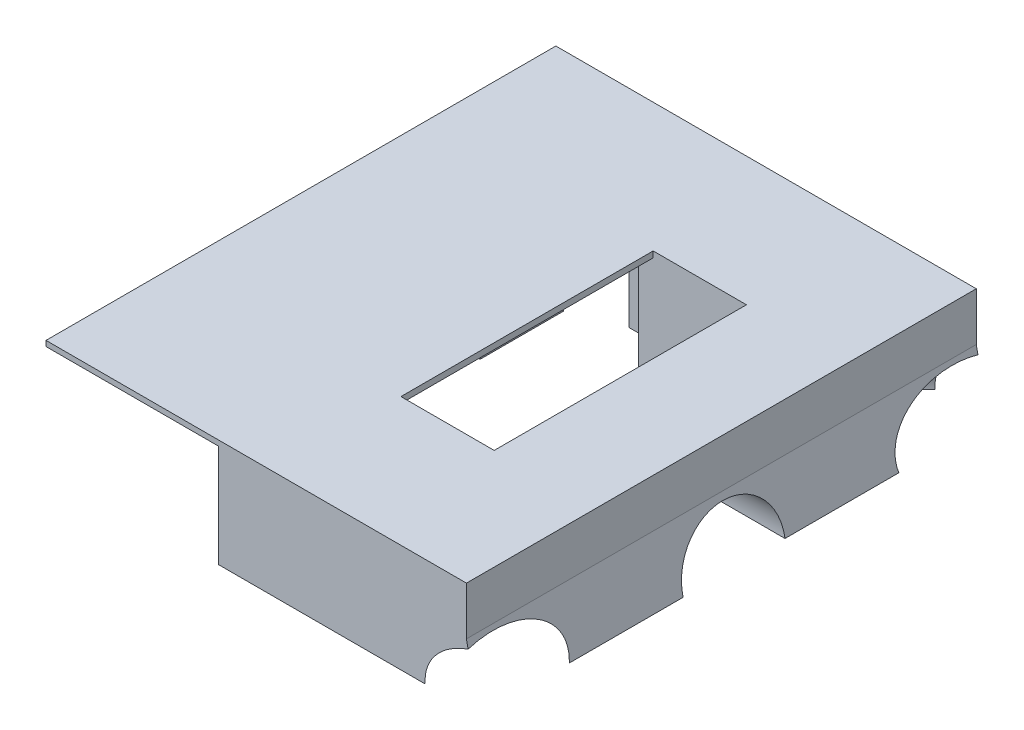
from build123d import *

# Parameters (mm, degrees)
SKETCH1_W           = 95
SKETCH1_H           = 95
BOSS_EXTRUDE1_DEPTH = 50
CUT_EXTRUDE1_DEPTH  = 100
SKETCH3_R           = 9.5
CUT_EXTRUDE2_DEPTH  = 45
CUT_EXTRUDE4_DEPTH  = 45
CUT_EXTRUDE5_DEPTH  = 45
CUT_EXTRUDE6_DEPTH  = 45
CUT_EXTRUDE7_DEPTH  = 45
SKETCH9_R           = 9.5
CUT_EXTRUDE9_DEPTH  = 45
SKETCH11_R          = 9.5
CUT_EXTRUDE10_DEPTH = 45
SKETCH12_W          = 31.985759797
SKETCH12_H          = 95
BOSS_EXTRUDE2_DEPTH = 45
CUT_EXTRUDE11_DEPTH = 100
SKETCH14_R          = 9.5
CUT_EXTRUDE12_DEPTH = 100
SKETCH15_R          = 9.5
CUT_EXTRUDE13_DEPTH = 100
SKETCH16_R          = 9.5
CUT_EXTRUDE14_DEPTH = 100
FILLET2_R           = 4
SKETCH17_W          = 34
SKETCH17_H          = 34
CUT_EXTRUDE16_DEPTH = 22
SKETCH19_W          = 34
SKETCH19_H          = 34
CUT_EXTRUDE17_DEPTH = 22
SKETCH20_W          = 12.5
SKETCH20_H          = 16.5
CUT_EXTRUDE18_DEPTH = 60
CUT_EXTRUDE19_DEPTH = 60
SKETCH22_W          = 99.816433395
SKETCH22_H          = 26.367590903
CUT_EXTRUDE21_DEPTH = 100
SKETCH23_R          = 1
CUT_EXTRUDE24_DEPTH = 909
SKETCH25_R          = 1
CUT_EXTRUDE25_DEPTH = 789
SKETCH27_W          = 26.129652456
SKETCH27_H          = 47
CUT_EXTRUDE27_DEPTH = 9
SKETCH28_W          = 2
SKETCH28_H          = 20
CUT_EXTRUDE28_DEPTH = 5
SKETCH29_W          = 99.017305209
SKETCH29_H          = 17.897343585
CUT_EXTRUDE29_DEPTH = 447
CUT_EXTRUDE30_DEPTH = 447
SKETCH31_W          = 26.129652456
SKETCH31_H          = 47
CUT_EXTRUDE31_DEPTH = 447
SKETCH32_W          = 12.716067022
SKETCH32_H          = 47
CUT_EXTRUDE32_DEPTH = 90
BOSS_EXTRUDE4_DEPTH = 9
SKETCH37_W          = 36.129652456
SKETCH37_H          = 47
CUT_EXTRUDE34_DEPTH = 9
SKETCH38_W          = 16
SKETCH38_H          = 58
CUT_EXTRUDE36_DEPTH = 19
SKETCH40_W          = 8.75
SKETCH40_H          = 1.118077743
BOSS_EXTRUDE5_DEPTH = 48
SKETCH41_W          = 47
SKETCH41_H          = 1.118077743
BOSS_EXTRUDE6_DEPTH = 10
SKETCH42_W          = 32.132900769
SKETCH42_H          = 1
BOSS_EXTRUDE7_DEPTH = 22
SKETCH43_W          = 32.132900769
SKETCH43_H          = 1.118077743
BOSS_EXTRUDE8_DEPTH = 22


with BuildPart() as part:
    # Sketch1 → Boss-Extrude1 (new body)
    with BuildSketch(Plane(origin=(0, 0, 0), x_dir=(1, 0, 0), z_dir=(0, 1, 0))):
        with Locations((-8.446550514, 2.043801884)):
            Rectangle(SKETCH1_W, SKETCH1_H)
    extrude(amount=BOSS_EXTRUDE1_DEPTH)

    # Sketch2 → Cut-Extrude1 (cut)
    with BuildSketch(Plane.XY.offset(45.456198116)):
        Polygon((39.053449486, 0), (36.353449486, 50), (39.053449486, 50), align=None)
    extrude(amount=-CUT_EXTRUDE1_DEPTH, mode=Mode.SUBTRACT)

    # Sketch3 → Cut-Extrude2 (cut)
    with BuildSketch(Plane(origin=(38.939900735, 2.10275464, 0), x_dir=(0, 0, -1), z_dir=(0.998545181, 0.05392144, 0))):
        with Locations((2.043801884, 13.394181776)):
            Circle(SKETCH3_R)
    extrude(amount=-CUT_EXTRUDE2_DEPTH, mode=Mode.SUBTRACT)

    # Sketch5 → Cut-Extrude4 (cut)
    with BuildSketch(Plane(origin=(0, 50, 0), x_dir=(1, 0, 0), z_dir=(0, 1, 0))):
        Polygon((39.053449486, 49.543801884), (39.053449486, 29.543801884), (19.053449486, 49.543801884), align=None)
        Polygon((39.053449486, -45.456198116), (39.053449486, -25.456198116), (19.053449486, -45.456198116), align=None)
    extrude(amount=-CUT_EXTRUDE4_DEPTH, mode=Mode.SUBTRACT)

    # Sketch6 → Cut-Extrude5 (cut)
    with BuildSketch(Plane(origin=(0, 50, 0), x_dir=(1, 0, 0), z_dir=(0, 1, 0))):
        Polygon((19.053449486, -45.456198116), (12.925569587, -39.328318218), (6.797689689, -45.456198116), align=None)
        Polygon((19.053449486, 49.543801884), (12.925569587, 43.415921985), (6.797689689, 49.543801884), align=None)
    extrude(amount=-CUT_EXTRUDE5_DEPTH, mode=Mode.SUBTRACT)

    # Sketch7 → Cut-Extrude6 (cut)
    with BuildSketch(Plane(origin=(-13.201374315, 0, 13.201374315), x_dir=(0.707106781, 0, 0.707106781), z_dir=(-0.707106781, 0, 0.707106781))):
        Polygon((45.615209271, 5), (42.915209271, 50), (45.615209271, 50), align=None)
    extrude(amount=-CUT_EXTRUDE6_DEPTH, mode=Mode.SUBTRACT)

    # Sketch8 → Cut-Extrude7 (cut)
    with BuildSketch(Plane(origin=(-15.245176199, 0, -15.245176199), x_dir=(-0.707106781, 0, 0.707106781), z_dir=(-0.707106781, 0, -0.707106781))):
        Polygon((-48.505581614, 5), (-45.805581614, 50), (-48.505581614, 50), align=None)
    extrude(amount=-CUT_EXTRUDE7_DEPTH, mode=Mode.SUBTRACT)

    # Sketch9 → Cut-Extrude9 (cut)
    with BuildSketch(Plane(origin=(34.386964646, 2.917830706, -34.386964646), x_dir=(-0.708373873, 0.059677836, -0.70331004), z_dir=(0.705837415, 0.059892291, -0.705837415))):
        with Locations((14.526974541, 11.311121921)):
            Circle(SKETCH9_R)
    extrude(amount=-CUT_EXTRUDE9_DEPTH, mode=Mode.SUBTRACT)

    # Sketch11 → Cut-Extrude10 (cut)
    with BuildSketch(Plane(origin=(32.350494057, 2.745030447, 32.350494057), x_dir=(0.70331004, 0.059677836, -0.708373873), z_dir=(0.705837415, 0.059892291, 0.705837415))):
        with Locations((-10.17752107, 12.964151979)):
            Circle(SKETCH11_R)
    extrude(amount=-CUT_EXTRUDE10_DEPTH, mode=Mode.SUBTRACT)

    # Sketch12 → Boss-Extrude2 (add)
    with BuildSketch(Plane(origin=(0, 5, 0), x_dir=(1, 0, 0), z_dir=(0, 1, 0))):
        with Locations((22.790569588, 2.043801884)):
            Rectangle(SKETCH12_W, SKETCH12_H)
    extrude(amount=BOSS_EXTRUDE2_DEPTH)

    # Sketch13 → Cut-Extrude11 (cut)
    with BuildSketch(Plane.XY.offset(45.456198116)):
        Polygon((39.053449486, 0), (29.053449486, 3), (19.053449486, 50), (49.745275601, 50), align=None)
    extrude(amount=-CUT_EXTRUDE11_DEPTH, mode=Mode.SUBTRACT)

    # Sketch14 → Cut-Extrude12 (cut)
    with BuildSketch(Plane(origin=(-5.994632406, -0.32371015, 0), x_dir=(0, 0, -1), z_dir=(0.998545181, 0.05392144, 0))):
        with Locations((2.043801884, 13.394181776)):
            Circle(SKETCH14_R)
    extrude(amount=CUT_EXTRUDE12_DEPTH, mode=Mode.SUBTRACT)

    # Sketch15 → Cut-Extrude13 (cut)
    with BuildSketch(Plane(origin=(0.587810371, 0.049877364, 0.587810371), x_dir=(0.70331004, 0.059677836, -0.708373873), z_dir=(0.705837415, 0.059892291, 0.705837415))):
        with Locations((-10.17752107, 12.964151979)):
            Circle(SKETCH15_R)
    extrude(amount=CUT_EXTRUDE13_DEPTH, mode=Mode.SUBTRACT)

    # Sketch16 → Cut-Extrude14 (cut)
    with BuildSketch(Plane(origin=(2.62428096, 0.222677624, -2.62428096), x_dir=(-0.708373873, 0.059677836, -0.70331004), z_dir=(0.705837415, 0.059892291, -0.705837415))):
        with Locations((14.526974541, 11.311121921)):
            Circle(SKETCH16_R)
    extrude(amount=CUT_EXTRUDE14_DEPTH, mode=Mode.SUBTRACT)

    # Fillet2
    fillet2_edges = [part.edges().sort_by_distance(p)[0] for p in [
        (29.053449486, 3, -2.043801884),
    ]]
    fillet(fillet2_edges, radius=FILLET2_R)

    # Sketch17 → Cut-Extrude16 (cut)
    with BuildSketch(Plane.XY.offset(45.456198116)):
        with Locations((-38.946550514, 17)):
            Rectangle(SKETCH17_W, SKETCH17_H)
    extrude(amount=-CUT_EXTRUDE16_DEPTH, mode=Mode.SUBTRACT)

    # Sketch19 → Cut-Extrude17 (cut)
    with BuildSketch(Plane(origin=(0, 0, -49.543801884), x_dir=(-1, 0, 0), z_dir=(0, 0, -1))):
        with Locations((38.946550514, 17)):
            Rectangle(SKETCH19_W, SKETCH19_H)
    extrude(amount=-CUT_EXTRUDE17_DEPTH, mode=Mode.SUBTRACT)

    # Sketch20 → Cut-Extrude18 (cut)
    with BuildSketch(Plane.XY.offset(23.456198116)):
        with Locations((-38.946550514, 12.25)):
            Rectangle(SKETCH20_W, SKETCH20_H)
    extrude(amount=-CUT_EXTRUDE18_DEPTH, mode=Mode.SUBTRACT)

    # Sketch21 → Cut-Extrude19 (cut)
    with BuildSketch(Plane.XY.offset(23.456198116)):
        Polygon((-55.946550514, 34), (-48.446550514, 0), (-55.946550514, 0), align=None)
    extrude(amount=-CUT_EXTRUDE19_DEPTH, mode=Mode.SUBTRACT)

    # Sketch22 → Cut-Extrude21 (cut)
    with BuildSketch(Plane.XY.offset(45.456198116)):
        with Locations((-7.85416812, 1.233943624)):
            Rectangle(SKETCH22_W, SKETCH22_H)
    extrude(amount=-CUT_EXTRUDE21_DEPTH, mode=Mode.SUBTRACT)

    # Sketch23 → Cut-Extrude24 (cut)
    with BuildSketch(Plane(origin=(0, 14.417739075, 0), x_dir=(-1, 0, 0), z_dir=(0, -1, 0))):
        with Locations((11.946550514, -35.456198116)):
            Circle(SKETCH23_R)
        with Locations((11.946550514, 39.543801884)):
            Circle(SKETCH23_R)
        with Locations((-16.624143299, -12.956198116)):
            Circle(SKETCH23_R)
        with Locations((-16.624143299, 17.043801884)):
            Circle(SKETCH23_R)
    extrude(amount=-CUT_EXTRUDE24_DEPTH, mode=Mode.SUBTRACT)

    # Sketch25 → Cut-Extrude25 (cut)
    with BuildSketch(Plane(origin=(0, 14.417739075, 0), x_dir=(-1, 0, 0), z_dir=(0, -1, 0))):
        with Locations((48.196550514, -13.456198116)):
            Circle(SKETCH25_R)
        with Locations((48.196550514, 17.543801884)):
            Circle(SKETCH25_R)
    extrude(amount=-CUT_EXTRUDE25_DEPTH, mode=Mode.SUBTRACT)

    # Sketch27 → Cut-Extrude27 (cut)
    with BuildSketch(Plane(origin=(0, 14.417739075, 0), x_dir=(-1, 0, 0), z_dir=(0, -1, 0))):
        with Locations((17.631724286, 2.043801884)):
            Rectangle(SKETCH27_W, SKETCH27_H)
    extrude(amount=-CUT_EXTRUDE27_DEPTH, mode=Mode.SUBTRACT)

    # Sketch28 → Cut-Extrude28 (cut)
    with BuildSketch(Plane(origin=(0, 14.417739075, 0), x_dir=(-1, 0, 0), z_dir=(0, -1, 0))):
        with Locations((31.696550514, 2.043801884)):
            Rectangle(SKETCH28_W, SKETCH28_H)
    extrude(amount=-CUT_EXTRUDE28_DEPTH, mode=Mode.SUBTRACT)

    # Sketch29 → Cut-Extrude29 (cut)
    with BuildSketch(Plane.XY.offset(45.456198116)):
        with Locations((-6.437897909, 42.948671793)):
            Rectangle(SKETCH29_W, SKETCH29_H)
    extrude(amount=-CUT_EXTRUDE29_DEPTH, mode=Mode.SUBTRACT)

    # Sketch30 → Cut-Extrude30 (cut)
    with BuildSketch(Plane.XY.offset(45.456198116)):
        Polygon((24.258594843, 25.535816818), (-54.079451283, 25.535816818), (-55.946550514, 34), (22.457704805, 34), align=None)
    extrude(amount=-CUT_EXTRUDE30_DEPTH, mode=Mode.SUBTRACT)

    # Sketch31 → Cut-Extrude31 (cut)
    with BuildSketch(Plane(origin=(0, 23.417739075, 0), x_dir=(-1, 0, 0), z_dir=(0, -1, 0))):
        with Locations((17.631724286, 2.043801884)):
            Rectangle(SKETCH31_W, SKETCH31_H)
    extrude(amount=-CUT_EXTRUDE31_DEPTH, mode=Mode.SUBTRACT)

    # Sketch32 → Cut-Extrude32 (cut)
    with BuildSketch(Plane(origin=(0, 14.417739075, 0), x_dir=(-1, 0, 0), z_dir=(0, -1, 0))):
        with Locations((0.924931569, 2.043801884)):
            Rectangle(SKETCH32_W, SKETCH32_H)
    extrude(amount=-CUT_EXTRUDE32_DEPTH, mode=Mode.SUBTRACT)

    # Sketch35 → Boss-Extrude4 (add)
    with BuildSketch(Plane(origin=(0, 25.535816818, 0), x_dir=(1, 0, 0), z_dir=(0, 1, 0))):
        Polygon((-54.079451283, 27.543801884), (-21.946550514, 27.543801884), (-21.946550514, 49.543801884), (24.258594843, 49.543801884), (24.258594843, -45.456198116), (-21.946550514, -45.456198116), (-21.946550514, -23.456198116), (-54.079451283, -23.456198116), align=None)
    extrude(amount=BOSS_EXTRUDE4_DEPTH)

    # Sketch37 → Cut-Extrude34 (cut)
    with BuildSketch(Plane(origin=(0, 25.535816818, 0), x_dir=(-1, 0, 0), z_dir=(0, -1, 0))):
        with Locations((12.631724286, 2.043801884)):
            Rectangle(SKETCH37_W, SKETCH37_H)
    extrude(amount=-CUT_EXTRUDE34_DEPTH, mode=Mode.SUBTRACT)

    # Sketch38 → Cut-Extrude36 (cut)
    with BuildSketch(Plane(origin=(0, 14.417739075, 0), x_dir=(-1, 0, 0), z_dir=(0, -1, 0))):
        with Locations((22.696550514, 2.043801884)):
            Rectangle(SKETCH38_W, SKETCH38_H)
    extrude(amount=-CUT_EXTRUDE36_DEPTH, mode=Mode.SUBTRACT)

    # Sketch40 → Boss-Extrude5 (add)
    with BuildSketch(Plane.XY.offset(-25.543801884)):
        with Locations((-26.321550514, 33.976777947)):
            Rectangle(SKETCH40_W, SKETCH40_H)
    extrude(amount=BOSS_EXTRUDE5_DEPTH)

    # Sketch41 → Boss-Extrude6 (add)
    with BuildSketch(Plane(origin=(-21.946550514, 0, 0), x_dir=(0, 0, -1), z_dir=(1, 0, 0))):
        with Locations((2.043801884, 33.976777947)):
            Rectangle(SKETCH41_W, SKETCH41_H)
    extrude(amount=BOSS_EXTRUDE6_DEPTH)

    # Sketch42 → Boss-Extrude7 (add)
    with BuildSketch(Plane.XY.offset(23.456198116)):
        with Locations((-38.013000899, 34.035816818)):
            Rectangle(SKETCH42_W, SKETCH42_H)
    extrude(amount=BOSS_EXTRUDE7_DEPTH)

    # Sketch43 → Boss-Extrude8 (add)
    with BuildSketch(Plane(origin=(0, 0, -27.543801884), x_dir=(-1, 0, 0), z_dir=(0, 0, -1))):
        with Locations((38.013000899, 33.976777947)):
            Rectangle(SKETCH43_W, SKETCH43_H)
    extrude(amount=BOSS_EXTRUDE8_DEPTH)


solid = part.part
